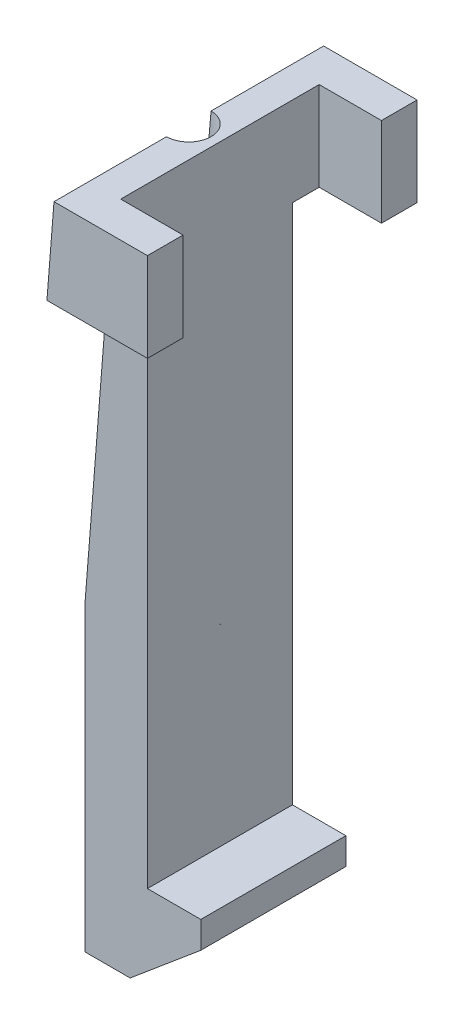
from build123d import *

# Parameters (mm, degrees)
BOSS_EXTRUDE2_START     = -0.2
BOSS_EXTRUDE2_DEPTH     = 1.63
SKETCH5_W               = 0.7
SKETCH5_H               = 1
BOSS_EXTRUDE4_DEPTH     = 0.7
SKETCH6_W               = 0.4
SKETCH6_H               = 1
BOSS_EXTRUDE5_DEPTH     = 0.7
CUT_EXTRUDE1_DEPTH      = 0.7
CUT_EXTRUDE1_DEPTH_BACK = 3.33
SKETCH7_R               = 0.25
CUT_EXTRUDE2_DEPTH      = 8.827352199


with BuildPart() as part:
    # Sketch2 → Boss-Extrude2 (new body)
    with BuildSketch(Plane.XY.offset(BOSS_EXTRUDE2_START)):
        Polygon((-0.5, 2.16), (-0.5, -4.7), (0.1, -4.7), (0.1, -5.000793217), (-0.694374061, -5.667352199), (-1.2, -5.667352199), (-1.2, 2.16), align=None)
    extrude(amount=-BOSS_EXTRUDE2_DEPTH)

    # Sketch5 → Boss-Extrude4 (add)
    with BuildSketch(Plane.XY.offset(-0.2)):
        with Locations((-0.85, 1.66)):
            Rectangle(SKETCH5_W, SKETCH5_H)
    boss_extrude4 = extrude(amount=BOSS_EXTRUDE4_DEPTH)

    # Sketch6 → Boss-Extrude5 (add)
    with BuildSketch(Plane(origin=(-0.5, 0, 0), x_dir=(0, 0, -1), z_dir=(1, 0, 0))):
        with Locations((-0.3, 1.66)):
            Rectangle(SKETCH6_W, SKETCH6_H)
    boss_extrude5 = extrude(amount=BOSS_EXTRUDE5_DEPTH)

    # Mirror1: Boss-Extrude4, Boss-Extrude5 across plane
    add(boss_extrude4.mirror(Plane.XY.offset(-1.015)))
    add(boss_extrude5.mirror(Plane.XY.offset(-1.015)))

    # Sketch3 → Cut-Extrude1 (cut, two sides)
    with BuildSketch(Plane.XY.offset(-0.2)) as cut_extrude1_sk:
        Polygon((-0.85, 2.16), (-1.2, -2.2536761), (-1.2, 2.16), align=None)
    extrude(amount=CUT_EXTRUDE1_DEPTH, mode=Mode.SUBTRACT)
    extrude(cut_extrude1_sk.sketch, amount=-CUT_EXTRUDE1_DEPTH_BACK, mode=Mode.SUBTRACT)

    # Sketch7 → Cut-Extrude2 (cut, through all)
    with BuildSketch(Plane(origin=(0, 2.16, 0), x_dir=(1, 0, 0), z_dir=(0, 1, 0))):
        with Locations((-0.85, 1.015)):
            Circle(SKETCH7_R)
    extrude(amount=-CUT_EXTRUDE2_DEPTH, mode=Mode.SUBTRACT)


solid = part.part
